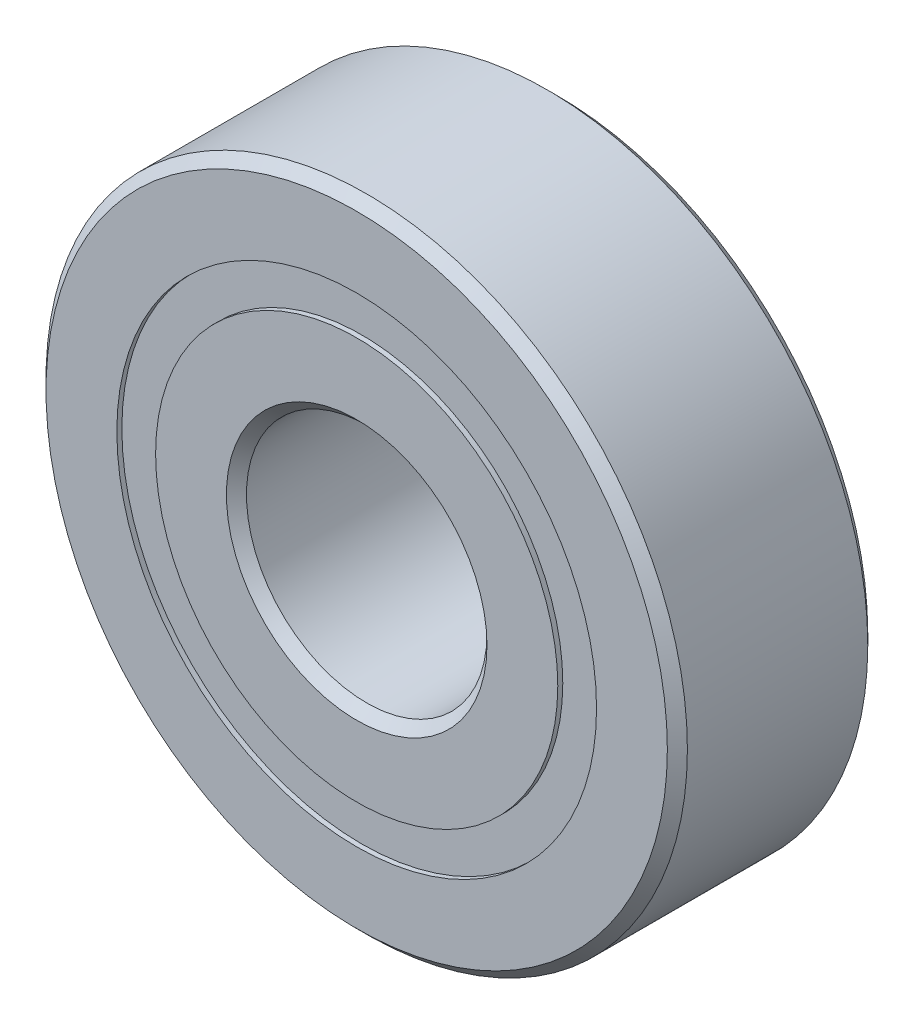
from build123d import *

# Parameters (mm, degrees)
CIRPATTERN1_COUNT = 12
SKETCH5_W         = 2.326485122
SKETCH5_H         = 1.934065934


with BuildPart() as part:
    # Sketch1 → Revolve1 (revolve)
    with BuildSketch(Plane(origin=(0, 0, 0), x_dir=(0, 0, -1), z_dir=(1, 0, 0))):
        with BuildLine():
            Line((4.5, 16), (-4.5, 16))
            Line((-4.5, 16), (-5, 15.5))
            Line((-5, 15.5), (-5, 11.967032967))
            Line((-5, 11.967032967), (-2.222222222, 11.967032967))
            ThreePointArc((-2.222222222, 11.967032967), (0, 13.423514878), (2.222222222, 11.967032967))
            Line((2.222222222, 11.967032967), (5, 11.967032967))
            Line((5, 11.967032967), (5, 15.5))
            Line((5, 15.5), (4.5, 16))
        make_face()
    revolve(axis=Axis((0, 0, 5), (0, 0, -1)))


with BuildPart() as body_2:
    # Sketch3 → Revolve3 (revolve)
    with BuildSketch(Plane(origin=(0, 0, 0), x_dir=(0, 0, -1), z_dir=(1, 0, 0))):
        with BuildLine():
            Line((-5, 10.032967033), (-2.222222222, 10.032967033))
            ThreePointArc((-2.222222222, 10.032967033), (0, 8.576485122), (2.222222222, 10.032967033))
            Line((2.222222222, 10.032967033), (5, 10.032967033))
            Line((5, 10.032967033), (5, 6.5))
            Line((5, 6.5), (4.5, 6))
            Line((4.5, 6), (-4.5, 6))
            Line((-4.5, 6), (-5, 6.5))
            Line((-5, 6.5), (-5, 10.032967033))
        make_face()
    revolve(axis=Axis((0, 0, 5), (0, 0, -1)))


with BuildPart() as body_3:
    # Sketch4 → Revolve4 (revolve)
    with BuildSketch(Plane(origin=(0, 0, 0), x_dir=(0, 0, -1), z_dir=(1, 0, 0))):
        with BuildLine():
            Line((-2.423514878, 11), (2.423514878, 11))
            ThreePointArc((2.423514878, 11), (0, 13.423514878), (-2.423514878, 11))
        make_face()
    revolve(axis=Axis((0, 11, 2.423514878), (0, 0, -1)))


with BuildPart() as cirpattern1_1:
    # CirPattern1: pattern copy
    add(body_3.part.rotate(Axis((0, 0, 0), (0, 0, 1)), 1 * 360 / CIRPATTERN1_COUNT))


with BuildPart() as cirpattern1_2:
    # CirPattern1: pattern copy
    add(body_3.part.rotate(Axis((0, 0, 0), (0, 0, 1)), 2 * 360 / CIRPATTERN1_COUNT))


with BuildPart() as cirpattern1_3:
    # CirPattern1: pattern copy
    add(body_3.part.rotate(Axis((0, 0, 0), (0, 0, 1)), 3 * 360 / CIRPATTERN1_COUNT))


with BuildPart() as cirpattern1_4:
    # CirPattern1: pattern copy
    add(body_3.part.rotate(Axis((0, 0, 0), (0, 0, 1)), 4 * 360 / CIRPATTERN1_COUNT))


with BuildPart() as cirpattern1_5:
    # CirPattern1: pattern copy
    add(body_3.part.rotate(Axis((0, 0, 0), (0, 0, 1)), 5 * 360 / CIRPATTERN1_COUNT))


with BuildPart() as cirpattern1_6:
    # CirPattern1: pattern copy
    add(body_3.part.rotate(Axis((0, 0, 0), (0, 0, 1)), 6 * 360 / CIRPATTERN1_COUNT))


with BuildPart() as cirpattern1_7:
    # CirPattern1: pattern copy
    add(body_3.part.rotate(Axis((0, 0, 0), (0, 0, 1)), 7 * 360 / CIRPATTERN1_COUNT))


with BuildPart() as cirpattern1_8:
    # CirPattern1: pattern copy
    add(body_3.part.rotate(Axis((0, 0, 0), (0, 0, 1)), 8 * 360 / CIRPATTERN1_COUNT))


with BuildPart() as cirpattern1_9:
    # CirPattern1: pattern copy
    add(body_3.part.rotate(Axis((0, 0, 0), (0, 0, 1)), 9 * 360 / CIRPATTERN1_COUNT))


with BuildPart() as cirpattern1_10:
    # CirPattern1: pattern copy
    add(body_3.part.rotate(Axis((0, 0, 0), (0, 0, 1)), 10 * 360 / CIRPATTERN1_COUNT))


with BuildPart() as cirpattern1_11:
    # CirPattern1: pattern copy
    add(body_3.part.rotate(Axis((0, 0, 0), (0, 0, 1)), 11 * 360 / CIRPATTERN1_COUNT))


with BuildPart() as body_15:
    # Sketch5 → Revolve5 (revolve)
    with BuildSketch(Plane(origin=(0, 0, 0), x_dir=(0, 0, -1), z_dir=(1, 0, 0))):
        with Locations((-3.586757439, 11)):
            Rectangle(SKETCH5_W, SKETCH5_H)
        with Locations((3.586757439, 11)):
            Rectangle(SKETCH5_W, SKETCH5_H)
    revolve(axis=Axis((0, 0, 5), (0, 0, -1)))


solid = Compound([part.part, body_2.part, body_3.part, cirpattern1_1.part, cirpattern1_2.part, cirpattern1_3.part, cirpattern1_4.part, cirpattern1_5.part, cirpattern1_6.part, cirpattern1_7.part, cirpattern1_8.part, cirpattern1_9.part, cirpattern1_10.part, cirpattern1_11.part, body_15.part])
